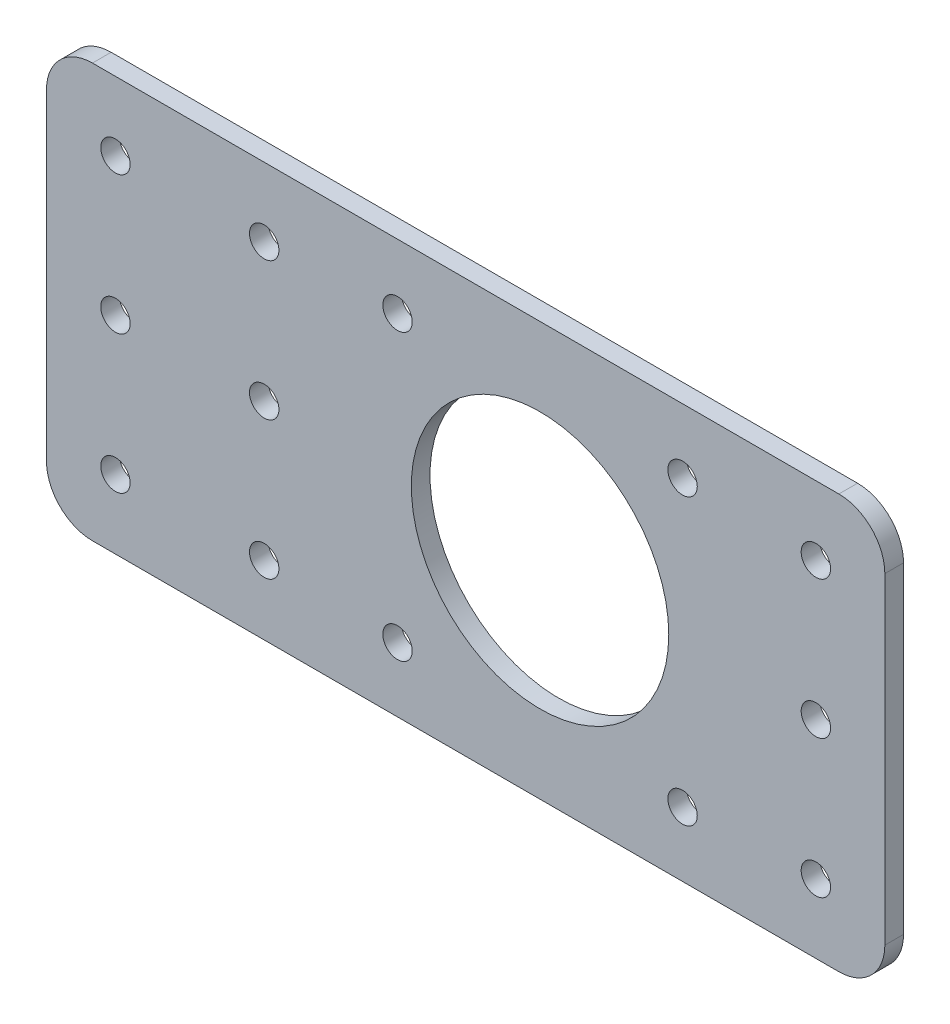
from build123d import *

# Parameters (mm, degrees)
SKETCH1_W           = 75
SKETCH1_H           = 45
SKETCH1_R           = 14
SKETCH1_R_2         = 1.6
BOSS_EXTRUDE1_DEPTH = 2.032
FILLET2_R           = 5
SKETCH2_R           = 1.6
CUT_EXTRUDE1_DEPTH  = 3.032
SKETCH5_W           = 21.294776471
SKETCH5_H           = 45
BOSS_EXTRUDE3_DEPTH = 2.032
FILLET3_R           = 5
SKETCH6_R           = 1.6
CUT_EXTRUDE2_DEPTH  = 3.032


with BuildPart() as part:
    # Sketch1 → Boss-Extrude1 (new body)
    with BuildSketch(Plane.XY):
        Rectangle(SKETCH1_W, SKETCH1_H)
        Circle(SKETCH1_R, mode=Mode.SUBTRACT)
        with Locations((-15.5, 15.5)):
            Circle(SKETCH1_R_2, mode=Mode.SUBTRACT)
        with Locations((15.5, 15.5)):
            Circle(SKETCH1_R_2, mode=Mode.SUBTRACT)
        with Locations((15.5, -15.5)):
            Circle(SKETCH1_R_2, mode=Mode.SUBTRACT)
        with Locations((-15.5, -15.5)):
            Circle(SKETCH1_R_2, mode=Mode.SUBTRACT)
    extrude(amount=BOSS_EXTRUDE1_DEPTH)

    # Fillet2
    fillet2_edges = [part.edges().sort_by_distance(p)[0] for p in [
        (37.5, -22.5, 1.016),
        (-37.5, -22.5, 1.016),
        (-37.5, 22.5, 1.016),
        (37.5, 22.5, 1.016),
    ]]
    fillet(fillet2_edges, radius=FILLET2_R)

    # Sketch2 → Cut-Extrude1 (cut, through all)
    with BuildSketch(Plane.XY.offset(2.032)):
        with Locations((-30, 0)):
            Circle(SKETCH2_R)
        with Locations((-30, 15)):
            Circle(SKETCH2_R)
        with Locations((-30, -15)):
            Circle(SKETCH2_R)
        with Locations((30, -15)):
            Circle(SKETCH2_R)
        with Locations((30, 15)):
            Circle(SKETCH2_R)
        with Locations((30, 0)):
            Circle(SKETCH2_R)
    extrude(amount=-CUT_EXTRUDE1_DEPTH, mode=Mode.SUBTRACT)

    # Sketch5 → Boss-Extrude3 (add)
    with BuildSketch(Plane.XY.offset(2.032)):
        with Locations((-43.032611765, 0)):
            Rectangle(SKETCH5_W, SKETCH5_H)
    extrude(amount=-BOSS_EXTRUDE3_DEPTH)

    # Fillet3
    fillet3_edges = [part.edges().sort_by_distance(p)[0] for p in [
        (-53.68, 22.5, 1.016),
        (-53.68, -22.5, 1.016),
    ]]
    fillet(fillet3_edges, radius=FILLET3_R)

    # Sketch6 → Cut-Extrude2 (cut, through all)
    with BuildSketch(Plane.XY.offset(2.032)):
        with Locations((-46.18, 15)):
            Circle(SKETCH6_R)
        with Locations((-46.18, 0)):
            Circle(SKETCH6_R)
        with Locations((-46.18, -15)):
            Circle(SKETCH6_R)
    extrude(amount=-CUT_EXTRUDE2_DEPTH, mode=Mode.SUBTRACT)


solid = part.part
